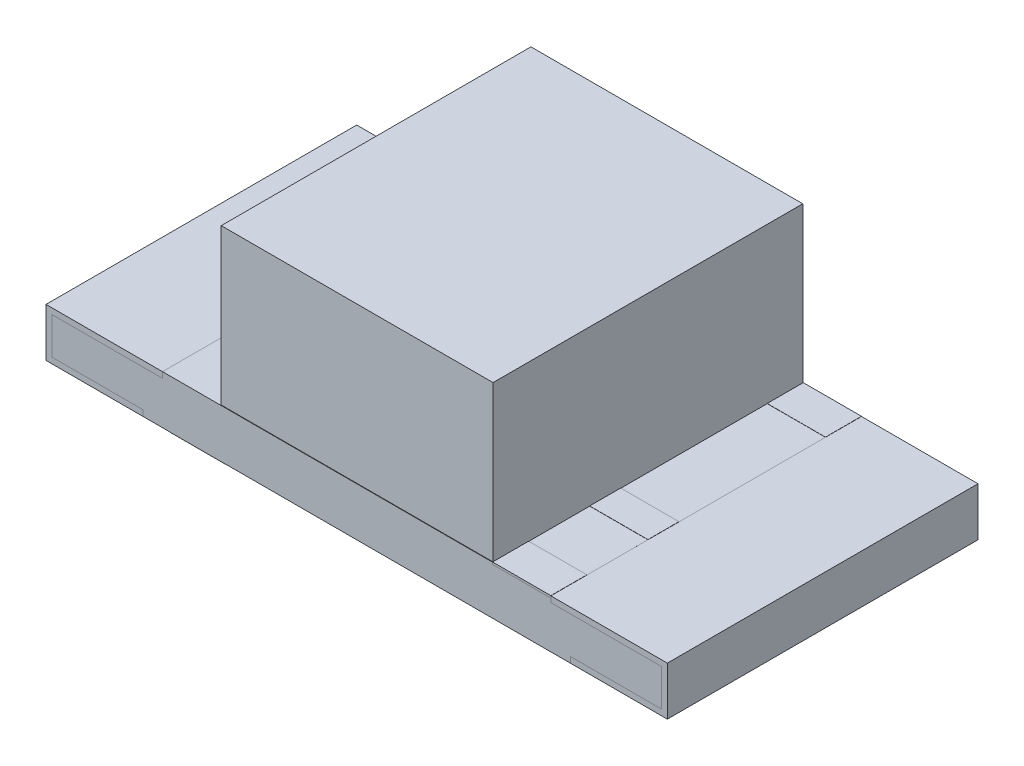
from build123d import *

# Parameters (mm, degrees)
EXTRUDE1_DEPTH        = 0.8
SKETCH1_5_W           = 1.4
SKETCH1_5_H           = 0.8
EXTRUDE5_DEPTH        = 0.7975
SKETCH2_W             = 1.442499651
SKETCH2_H             = 0.480833216
EXTRUDE6_DEPTH        = 0.001
EXTRUDE6_DEPTH_BACK   = 0.01
EXTRUDE7_DEPTH        = 0.8
EXTRUDE7_2_DEPTH      = 0.8
SKETCH5_W             = 0.3
SKETCH5_H             = 0.159637188
EXTRUDE8_DEPTH        = 0.001
EXTRUDE8_DEPTH_BACK   = 0.01
EXTRUDE8_2_DEPTH      = 0.001
EXTRUDE8_2_DEPTH_BACK = 0.01
EXTRUDE9_DEPTH        = 0.001
EXTRUDE9_DEPTH_BACK   = 0.01
EXTRUDE9_2_DEPTH      = 0.001
EXTRUDE9_2_DEPTH_BACK = 0.01


with BuildPart() as part:
    # Sketch1 → Extrude1 (new body, symmetric)
    with BuildSketch(Plane.XY):
        Polygon((-0.7, 0.125), (-1, 0.125), (-1, 0.095), (-1.57, 0.095), (-1.57, -0.095), (-1.1, -0.095), (-1.1, -0.125), (1.1, -0.125), (1.1, -0.095), (1.57, -0.095), (1.57, 0.095), (1, 0.095), (1, 0.125), (0.7, 0.125), (0.075, 0.125), (-0.075, 0.125), align=None)
    extrude(amount=EXTRUDE1_DEPTH, both=True)

    # Sketch1_5 → Extrude5 (add, symmetric)
    with BuildSketch(Plane.XY):
        with Locations((0, 0.525)):
            Rectangle(SKETCH1_5_W, SKETCH1_5_H)
    extrude(amount=EXTRUDE5_DEPTH, both=True)


with BuildPart() as body_2:
    # Sketch2 → Extrude6 (new body, two sides)
    with BuildSketch(Plane.XZ.offset(0.125)) as extrude6_sk:
        Polygon((-0.671163032, 0.8), (-0.965005553, 0.8), (-0.965005553, -0.8), (-0.671163032, -0.8), (-0.671163032, -0.240416608), (-0.671163032, 0.240416608), align=None)
        with Locations((0.050086794, 0)):
            Rectangle(SKETCH2_W, SKETCH2_H)
    extrude(amount=EXTRUDE6_DEPTH)
    extrude(extrude6_sk.sketch, amount=-EXTRUDE6_DEPTH_BACK)


with BuildPart() as body_3:
    # Sketch1_6 → Extrude7 (new body, symmetric)
    with BuildSketch(Plane.XY):
        Polygon((-1, 0.125), (-1.6, 0.125), (-1.6, -0.125), (-1.1, -0.125), (-1.1, -0.095), (-1.57, -0.095), (-1.57, 0.095), (-1, 0.095), align=None)
    extrude(amount=EXTRUDE7_DEPTH, both=True)


with BuildPart() as body_4:
    # Sketch1_6 → Extrude7 2 (new body, symmetric)
    with BuildSketch(Plane.XY):
        Polygon((1.1, -0.095), (1.1, -0.125), (1.6, -0.125), (1.6, 0.125), (1, 0.125), (1, 0.095), (1.57, 0.095), (1.57, -0.095), align=None)
    extrude(amount=EXTRUDE7_2_DEPTH, both=True)


with BuildPart() as body_5:
    # Sketch5 → Extrude8 (new body, two sides)
    with BuildSketch(Plane(origin=(0, 0.125, 0), x_dir=(-1, 0, 0), z_dir=(0, 1, 0))) as extrude8_sk:
        with Locations((0.85, 0.22010582)):
            Rectangle(SKETCH5_W, SKETCH5_H)
    extrude(amount=EXTRUDE8_DEPTH)
    extrude(extrude8_sk.sketch, amount=-EXTRUDE8_DEPTH_BACK)


with BuildPart() as body_6:
    # Sketch5 → Extrude8 2 (new body, two sides)
    with BuildSketch(Plane(origin=(0, 0.125, 0), x_dir=(-1, 0, 0), z_dir=(0, 1, 0))) as extrude8_2_sk:
        with Locations((-0.85, 0.22010582)):
            Rectangle(SKETCH5_W, SKETCH5_H)
    extrude(amount=EXTRUDE8_2_DEPTH)
    extrude(extrude8_2_sk.sketch, amount=-EXTRUDE8_2_DEPTH_BACK)


with BuildPart() as body_7:
    # Sketch5_3 → Extrude9 (new body, two sides)
    with BuildSketch(Plane(origin=(0, 0.125, 0), x_dir=(-1, 0, 0), z_dir=(0, 1, 0))) as extrude9_sk:
        Polygon((-0.7, -0.6143613), (-1, -0.6143613), (-1, -0.8), (-0.7, -0.8), (-0.7, -0.7975), align=None)
    extrude(amount=EXTRUDE9_DEPTH)
    extrude(extrude9_sk.sketch, amount=-EXTRUDE9_DEPTH_BACK)


with BuildPart() as body_8:
    # Sketch5_3 → Extrude9 2 (new body, two sides)
    with BuildSketch(Plane(origin=(0, 0.125, 0), x_dir=(-1, 0, 0), z_dir=(0, 1, 0))) as extrude9_2_sk:
        Polygon((-0.7, 0.8), (-1, 0.8), (-1, 0.6143613), (-0.7, 0.6143613), (-0.7, 0.7975), align=None)
    extrude(amount=EXTRUDE9_2_DEPTH)
    extrude(extrude9_2_sk.sketch, amount=-EXTRUDE9_2_DEPTH_BACK)


solid = Compound([part.part, body_2.part, body_3.part, body_4.part, body_5.part, body_6.part, body_7.part, body_8.part])
